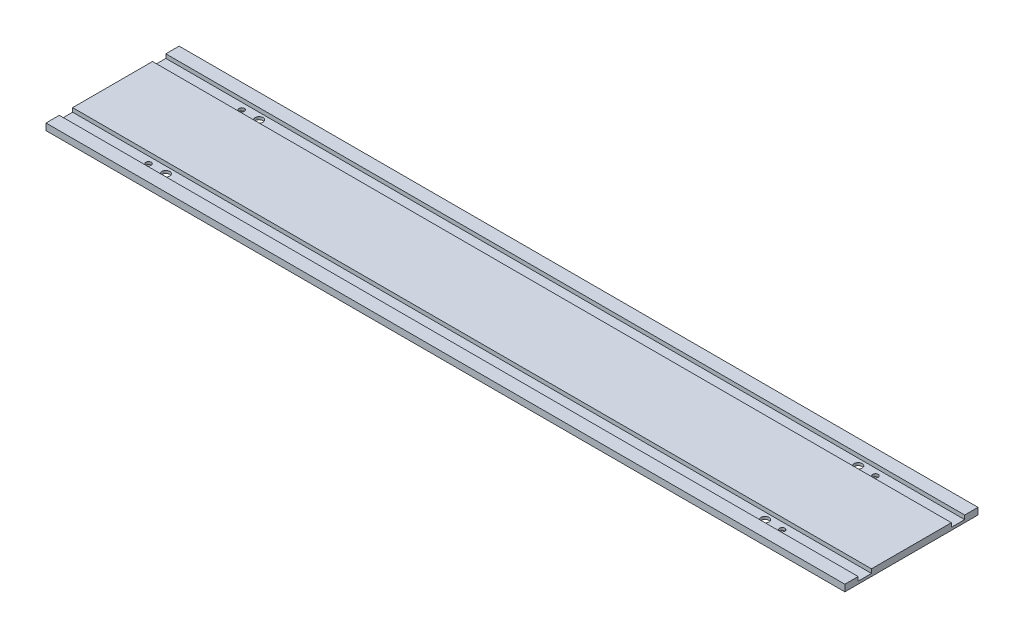
from build123d import *

# Parameters (mm, degrees)
SKETCH1_W           = 600
SKETCH1_H           = 5
BOSS_EXTRUDE1_DEPTH = 100
SKETCH5_W           = 600
SKETCH5_H           = 10
CUT_EXTRUDE1_DEPTH  = 3
SKETCH6_R           = 2
CUT_EXTRUDE2_DEPTH  = 6
SKETCH7_R           = 3
CUT_EXTRUDE3_DEPTH  = 6


with BuildPart() as part:
    # Sketch1 → Boss-Extrude1 (new body)
    with BuildSketch(Plane.XY):
        with Locations((300, 2.5)):
            Rectangle(SKETCH1_W, SKETCH1_H)
    extrude(amount=-BOSS_EXTRUDE1_DEPTH)

    # Sketch5 → Cut-Extrude1 (cut)
    with BuildSketch(Plane(origin=(0, 5, 0), x_dir=(1, 0, 0), z_dir=(0, 1, 0))):
        with Locations((300, 85)):
            Rectangle(SKETCH5_W, SKETCH5_H)
        with Locations((300, 15)):
            Rectangle(SKETCH5_W, SKETCH5_H)
    extrude(amount=-CUT_EXTRUDE1_DEPTH, mode=Mode.SUBTRACT)

    # Sketch6 → Cut-Extrude2 (cut, through all)
    with BuildSketch(Plane(origin=(0, 5, 0), x_dir=(1, 0, 0), z_dir=(0, 1, 0))):
        with Locations((62, 85)):
            Circle(SKETCH6_R)
        with Locations((62, 15)):
            Circle(SKETCH6_R)
        with Locations((538, 85)):
            Circle(SKETCH6_R)
        with Locations((538, 15)):
            Circle(SKETCH6_R)
    extrude(amount=-CUT_EXTRUDE2_DEPTH, mode=Mode.SUBTRACT)

    # Sketch7 → Cut-Extrude3 (cut, through all)
    with BuildSketch(Plane(origin=(0, 5, 0), x_dir=(1, 0, 0), z_dir=(0, 1, 0))):
        with Locations((75, 85)):
            Circle(SKETCH7_R)
        with Locations((75, 15)):
            Circle(SKETCH7_R)
        with Locations((525, 85)):
            Circle(SKETCH7_R)
        with Locations((525, 15)):
            Circle(SKETCH7_R)
    extrude(amount=-CUT_EXTRUDE3_DEPTH, mode=Mode.SUBTRACT)


solid = part.part
